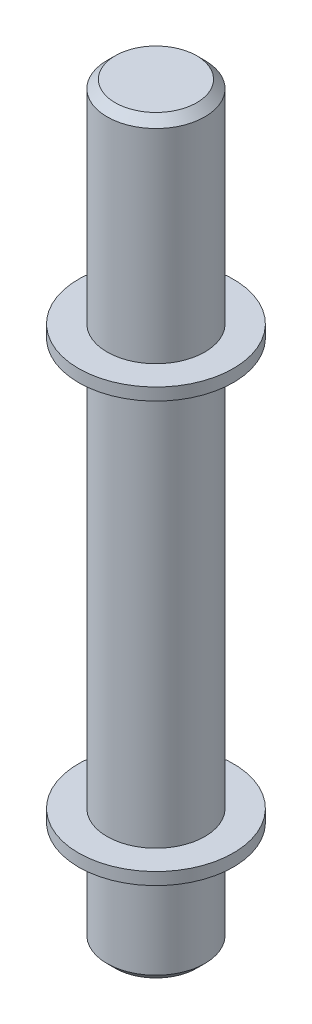
from build123d import *

# Parameters (mm, degrees)
CHAMFER3_SIZE = 2


with BuildPart() as part:
    # Sketch1 → Revolve1 (revolve)
    with BuildSketch(Plane(origin=(0, 0, 0), x_dir=(0, 0, -1), z_dir=(1, 0, 0))):
        Polygon((0, 0), (12, 0), (12, 26), (19, 26), (19, 29), (12, 29), (12, 129), (19, 129), (19, 132), (12, 132), (12, 184), (0, 184), align=None)
    revolve(axis=Axis((0, 184, 0), (0, -1, 0)))

    # Chamfer3
    chamfer3_edges = [part.edges().sort_by_distance(p)[0] for p in [
        (0, 0, 12),
        (0, 184, 12),
    ]]
    chamfer(chamfer3_edges, length=CHAMFER3_SIZE)


solid = part.part
